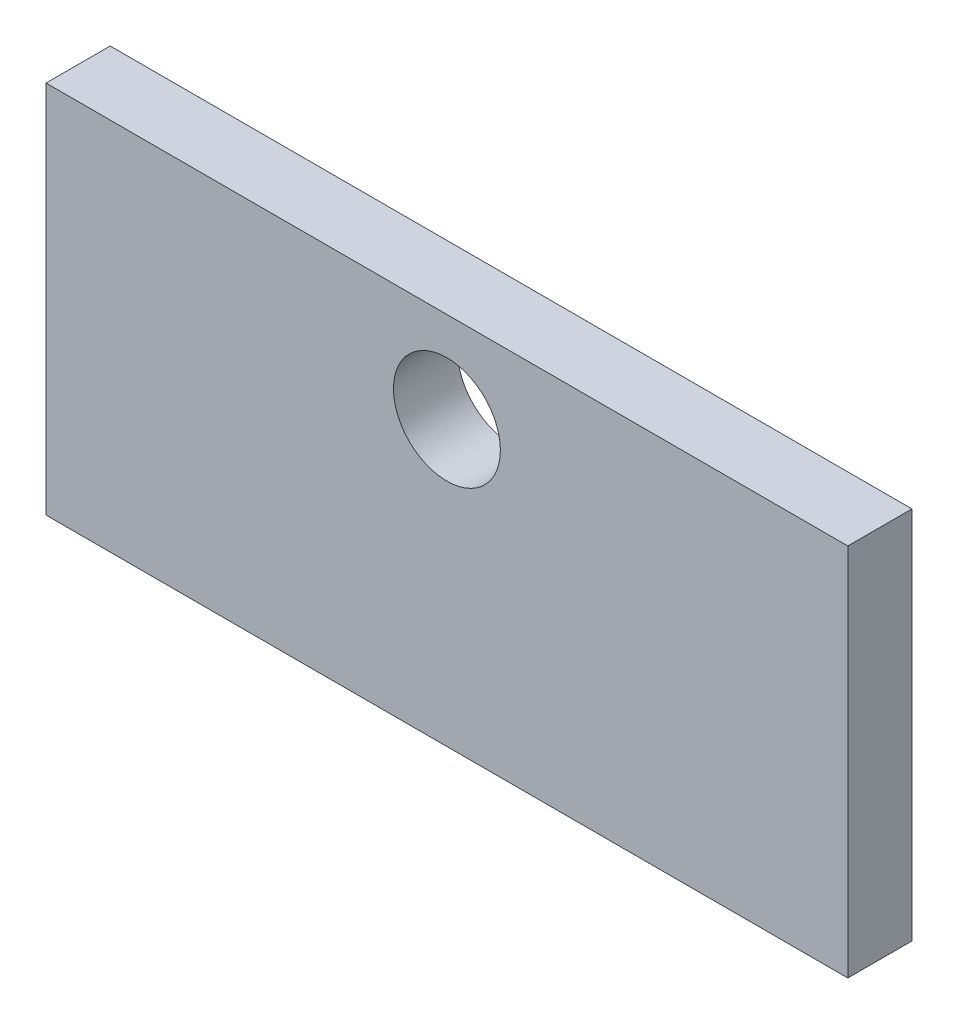
from build123d import *

# Parameters (mm, degrees)
CROQUIS1_W              = 150
CROQUIS1_H              = 70
SALIENTE_EXTRUIR1_DEPTH = 12
CROQUIS3_R              = 10
CORTAR_EXTRUIR1_DEPTH   = 13


with BuildPart() as part:
    # Croquis1 → Saliente-Extruir1 (new body)
    with BuildSketch(Plane.XY):
        with Locations((75, 35)):
            Rectangle(CROQUIS1_W, CROQUIS1_H)
    extrude(amount=SALIENTE_EXTRUIR1_DEPTH)

    # Croquis3 → Cortar-Extruir1 (cut, through all)
    with BuildSketch(Plane.XY.offset(12)):
        with Locations((75, 53)):
            Circle(CROQUIS3_R)
    extrude(amount=-CORTAR_EXTRUIR1_DEPTH, mode=Mode.SUBTRACT)


solid = part.part
